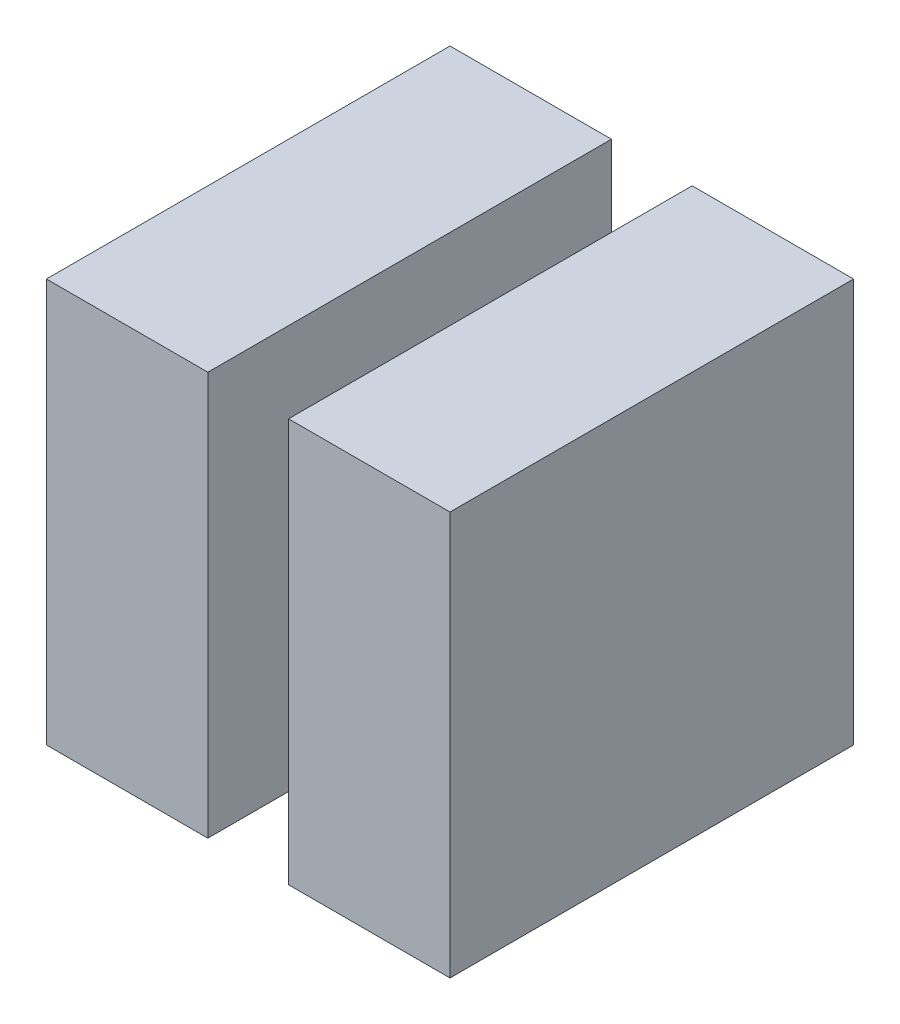
from build123d import *

# Parameters (mm, degrees)
SZKIC1_W                    = 20
SZKIC1_H                    = 50
DODANIE_WYCI_GNI_CIE1_DEPTH = 50
SZYK_LINIOWY1_COUNT         = 2
SZYK_LINIOWY1_PITCH         = 30


with BuildPart() as part:
    # Szkic1 → Dodanie-wyciągnięcie1 (new body)
    with BuildSketch(Plane.XY):
        with Locations((10, 25)):
            Rectangle(SZKIC1_W, SZKIC1_H)
    extrude(amount=DODANIE_WYCI_GNI_CIE1_DEPTH)


with BuildPart() as szyk_liniowy1_1:
    # Szyk liniowy1: pattern copy
    add(part.part.moved(Location(Vector(1, 0, 0) * (1 * SZYK_LINIOWY1_PITCH))))


solid = Compound([part.part, szyk_liniowy1_1.part])
